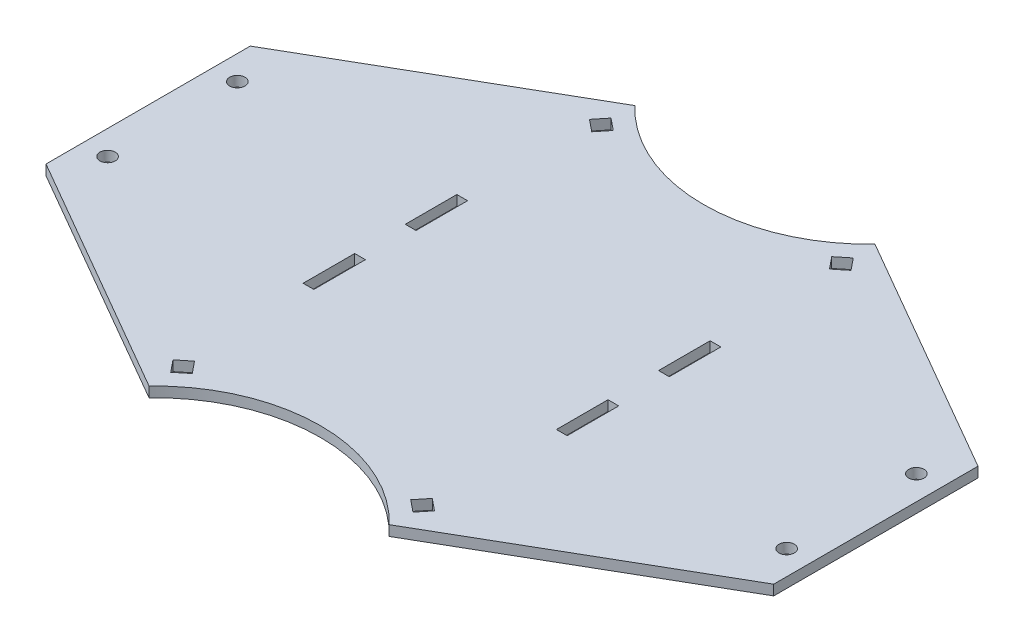
from build123d import *

# Parameters (mm, degrees)
ESQUISSE1_R             = 197.5
BOSS_EXTRU_1_DEPTH      = 4
ENL_V_START             = -1
ESQUISSE3_R             = 3
ENL_V_MAT_EXTRU_2_DEPTH = 6
ENL_V_MAT_EXTRU_5_DEPTH = 5
ESQUISSE6_W             = 4.2
ESQUISSE6_H             = 20.2
ENL_V_MAT_EXTRU_8_DEPTH = 5
ENL_V_MAT_EXTRU_6_DEPTH = 5
CUT_EXTRUDE1_DEPTH      = 5
MIRROR5_COPY_1_DEPTH    = 5
CUT_EXTRUDE2_DEPTH      = 5
MIRROR7_COPY_1_DEPTH    = 5


with BuildPart() as part:
    # Esquisse1 → Boss.-Extru.1 (new body)
    with BuildSketch(Plane(origin=(0, 0, 0), x_dir=(1, 0, 0), z_dir=(0, 1, 0))):
        Circle(ESQUISSE1_R)
    extrude(amount=BOSS_EXTRU_1_DEPTH)

    # Esquisse3 → Enlèv. mat.-Extru.2 (cut)
    with BuildSketch(Plane(origin=(0, 0, 0), x_dir=(1, 0, 0), z_dir=(0, 1, 0)).offset(ENL_V_START)):
        with Locations((-132.97, 25.4)):
            Circle(ESQUISSE3_R)
        with Locations((-132.97, -25.4)):
            Circle(ESQUISSE3_R)
        with BuildLine():
            Line((-180.572007797, 80), (-157.5, 80))
            ThreePointArc((-157.5, 80), (-146.893398282, 75.606601718), (-142.5, 65))
            Line((-142.5, 65), (-142.5, -65))
            ThreePointArc((-142.5, -65), (-146.893398282, -75.606601718), (-157.5, -80))
            Line((-157.5, -80), (-180.572007797, -80))
            ThreePointArc((-180.572007797, -80), (-197.5, 0), (-180.572007797, 80))
        make_face()
    enl_v_mat_extru_2 = extrude(amount=ENL_V_MAT_EXTRU_2_DEPTH, mode=Mode.SUBTRACT)

    # Esquisse4 → Enlèv. mat.-Extru.5 (cut, through all)
    with BuildSketch(Plane(origin=(0, 0, 0), x_dir=(1, 0, 0), z_dir=(0, 1, 0))):
        with BuildLine():
            Line((-107.5, 110), (-107.5, 90))
            ThreePointArc((-107.5, 90), (-104.571067812, 82.928932188), (-97.5, 80))
            Line((-97.5, 80), (-82.5, 80))
            ThreePointArc((-82.5, 80), (-75.428932188, 82.928932188), (-72.5, 90))
            Line((-72.5, 90), (-72.5, 110))
            ThreePointArc((-72.5, 110), (-75.428932188, 117.071067812), (-82.5, 120))
            Line((-82.5, 120), (-97.5, 120))
            ThreePointArc((-97.5, 120), (-104.571067812, 117.071067812), (-107.5, 110))
        make_face()
    enl_v_mat_extru_5 = extrude(amount=ENL_V_MAT_EXTRU_5_DEPTH, mode=Mode.SUBTRACT)

    # Esquisse6 → Enlèv. mat.-Extru.8 (cut, through all)
    with BuildSketch(Plane(origin=(0, 0, 0), x_dir=(1, 0, 0), z_dir=(0, 1, 0))):
        with Locations((-49.6, 20)):
            Rectangle(ESQUISSE6_W, ESQUISSE6_H)
        with Locations((-49.6, -20)):
            Rectangle(ESQUISSE6_W, ESQUISSE6_H)
    enl_v_mat_extru_8 = extrude(amount=ENL_V_MAT_EXTRU_8_DEPTH, mode=Mode.SUBTRACT)

    # Mirror1: Enlèv. mat.-Extru.2, Enlèv. mat.-Extru.5, Enlèv. mat.-Extru.8 across plane
    add(enl_v_mat_extru_2.mirror(Plane(origin=(0, 0, 0), x_dir=(0, 0, 1), z_dir=(1, 0, 0))), mode=Mode.SUBTRACT)
    add(enl_v_mat_extru_5.mirror(Plane(origin=(0, 0, 0), x_dir=(0, 0, 1), z_dir=(1, 0, 0))), mode=Mode.SUBTRACT)
    add(enl_v_mat_extru_8.mirror(Plane(origin=(0, 0, 0), x_dir=(0, 0, 1), z_dir=(1, 0, 0))), mode=Mode.SUBTRACT)

    # Esquisse5 → Enlèv. mat.-Extru.6 (cut, through all)
    with BuildSketch(Plane(origin=(0, 0, 0), x_dir=(1, 0, 0), z_dir=(0, 1, 0))):
        with BuildLine():
            Line((-65, 140), (-65, 186.497319016))
            ThreePointArc((-65, 186.497319016), (0, 197.5), (65, 186.497319016))
            Line((65, 186.497319016), (65, 140))
            ThreePointArc((65, 140), (0, 75), (-65, 140))
        make_face()
    enl_v_mat_extru_6 = extrude(amount=ENL_V_MAT_EXTRU_6_DEPTH, mode=Mode.SUBTRACT)

    # Mirror2: Enlèv. mat.-Extru.6 across plane
    add(enl_v_mat_extru_6.mirror(Plane.XY), mode=Mode.SUBTRACT)

    # Sketch1 → Cut-Extrude1 (cut, through all)
    with BuildSketch(Plane(origin=(0, 4, 0), x_dir=(1, 0, 0), z_dir=(0, 1, 0))):
        Polygon((-47.442047988, -86.219548978), (-51.219548978, -81.557952012), (-46.557952012, -77.780451022), (-42.780451022, -82.442047988), align=None)
    cut_extrude1 = extrude(amount=-CUT_EXTRUDE1_DEPTH, mode=Mode.SUBTRACT)

    # Mirror4: Cut-Extrude1 across plane
    add(cut_extrude1.mirror(Plane.XY), mode=Mode.SUBTRACT)

    # Mirror5: Cut-Extrude1 across plane
    add(cut_extrude1.mirror(Plane(origin=(0, 0, 0), x_dir=(0, 0, 1), z_dir=(1, 0, 0))), mode=Mode.SUBTRACT)

    # Mirror5 copy 1 sketch → Mirror5 copy 1 (cut, through all)
    with BuildSketch(Plane(origin=(0, 4, 0), x_dir=(-1, 0, 0), z_dir=(0, 1, 0))):
        Polygon((-47.442047988, -86.219548978), (-51.219548978, -81.557952012), (-46.557952012, -77.780451022), (-42.780451022, -82.442047988), align=None)
    extrude(amount=-MIRROR5_COPY_1_DEPTH, mode=Mode.SUBTRACT)

    # Sketch3 → Cut-Extrude2 (cut, through all)
    with BuildSketch(Plane(origin=(0, 4, 0), x_dir=(1, 0, 0), z_dir=(0, 1, 0))):
        Polygon((-47.022675211, 95.123859168), (-142.5, 40), (-180.572007797, 80), (-180.572007797, 186.497319016), (-65, 186.497319016), align=None)
    cut_extrude2 = extrude(amount=-CUT_EXTRUDE2_DEPTH, mode=Mode.SUBTRACT)

    # Mirror6: Cut-Extrude2 across plane
    add(cut_extrude2.mirror(Plane.XY), mode=Mode.SUBTRACT)

    # Mirror7: Cut-Extrude2 across plane
    add(cut_extrude2.mirror(Plane(origin=(0, 0, 0), x_dir=(0, 0, 1), z_dir=(1, 0, 0))), mode=Mode.SUBTRACT)

    # Mirror7 copy 1 sketch → Mirror7 copy 1 (cut, through all)
    with BuildSketch(Plane(origin=(0, 4, 0), x_dir=(-1, 0, 0), z_dir=(0, 1, 0))):
        Polygon((-47.022675211, 95.123859168), (-142.5, 40), (-180.572007797, 80), (-180.572007797, 186.497319016), (-65, 186.497319016), align=None)
    extrude(amount=-MIRROR7_COPY_1_DEPTH, mode=Mode.SUBTRACT)


solid = part.part
